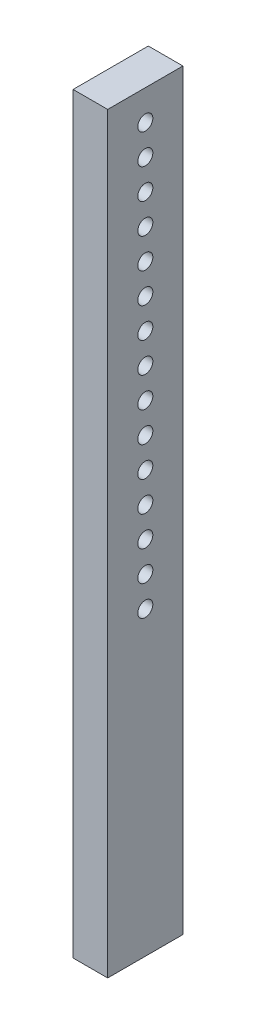
from build123d import *

# Parameters (mm, degrees)
SKETCH1_W           = 50
SKETCH1_H           = 500
SKETCH1_R           = 5
BOSS_EXTRUDE1_DEPTH = 23


with BuildPart() as part:
    # Sketch1 → Boss-Extrude1 (new body)
    with BuildSketch(Plane(origin=(0, 0, 0), x_dir=(0, 0, -1), z_dir=(1, 0, 0))):
        Rectangle(SKETCH1_W, SKETCH1_H)
        with Locations((0, 230)):
            Circle(SKETCH1_R, mode=Mode.SUBTRACT)
        with Locations((0, 210)):
            Circle(SKETCH1_R, mode=Mode.SUBTRACT)
        with Locations((0, 190)):
            Circle(SKETCH1_R, mode=Mode.SUBTRACT)
        with Locations((0, 170)):
            Circle(SKETCH1_R, mode=Mode.SUBTRACT)
        with Locations((0, 150)):
            Circle(SKETCH1_R, mode=Mode.SUBTRACT)
        with Locations((0, 130)):
            Circle(SKETCH1_R, mode=Mode.SUBTRACT)
        with Locations((0, 110)):
            Circle(SKETCH1_R, mode=Mode.SUBTRACT)
        with Locations((0, 90)):
            Circle(SKETCH1_R, mode=Mode.SUBTRACT)
        with Locations((0, 70)):
            Circle(SKETCH1_R, mode=Mode.SUBTRACT)
        with Locations((0, 50)):
            Circle(SKETCH1_R, mode=Mode.SUBTRACT)
        with Locations((0, 30)):
            Circle(SKETCH1_R, mode=Mode.SUBTRACT)
        with Locations((0, 10)):
            Circle(SKETCH1_R, mode=Mode.SUBTRACT)
        with Locations((0, -10)):
            Circle(SKETCH1_R, mode=Mode.SUBTRACT)
        with Locations((0, -30)):
            Circle(SKETCH1_R, mode=Mode.SUBTRACT)
        with Locations((0, -50)):
            Circle(SKETCH1_R, mode=Mode.SUBTRACT)
    extrude(amount=BOSS_EXTRUDE1_DEPTH)


solid = part.part
